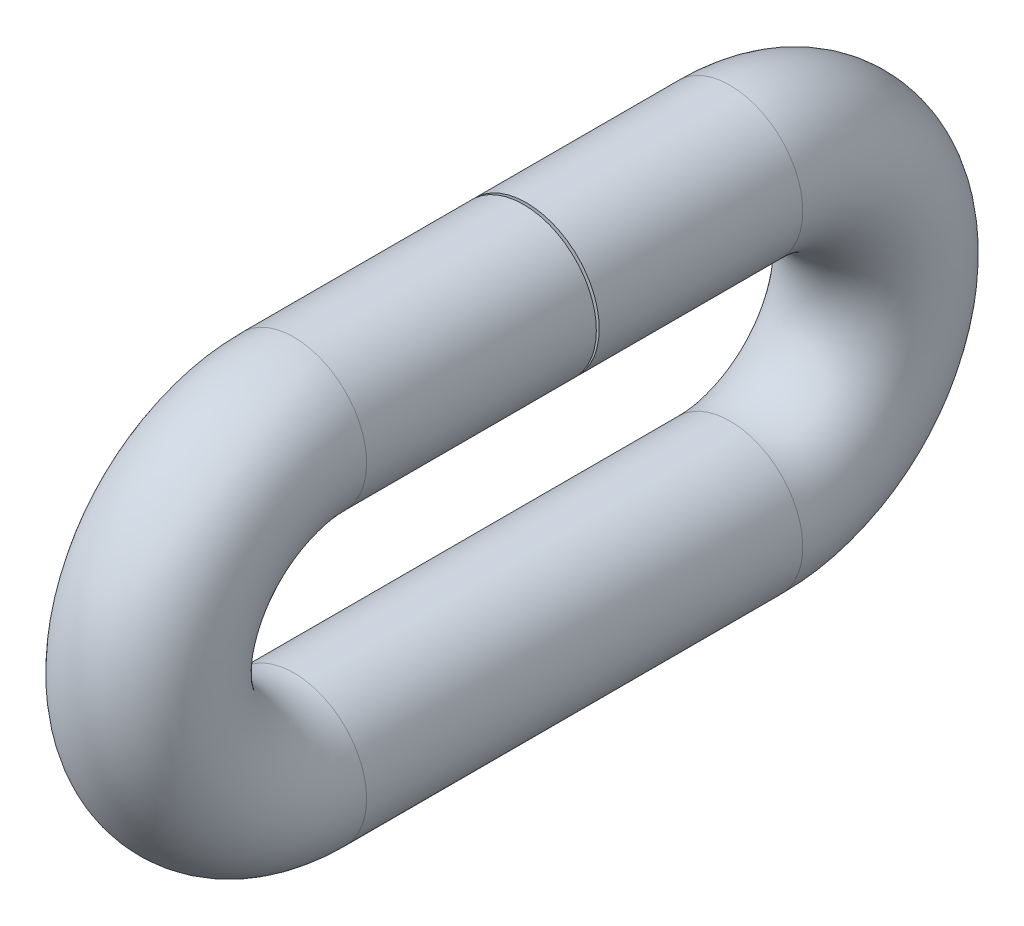
from build123d import *

# Parameters (mm, degrees)
SKETCH1_R = 63.5


with BuildPart() as part:
    # Sweep1: sweep along a path in Sketch2
    with BuildLine(Plane(origin=(0, 0, 0), x_dir=(0, 0, -1), z_dir=(1, 0, 0))) as sweep1_path:
        Line((0, 0), (177.8, 0))
        ThreePointArc((177.8, 0), (304.8, -127), (177.8, -254))
        Line((177.8, -254), (-203.2, -254))
        ThreePointArc((-203.2, -254), (-330.2, -127), (-203.2, 0))
        Line((-203.2, 0), (-2.54, 0))
    # Sketch1 → Sweep1 (sweep)
    with BuildSketch(Plane.XY):
        Circle(SKETCH1_R)
    sweep(path=sweep1_path.line)


solid = part.part
